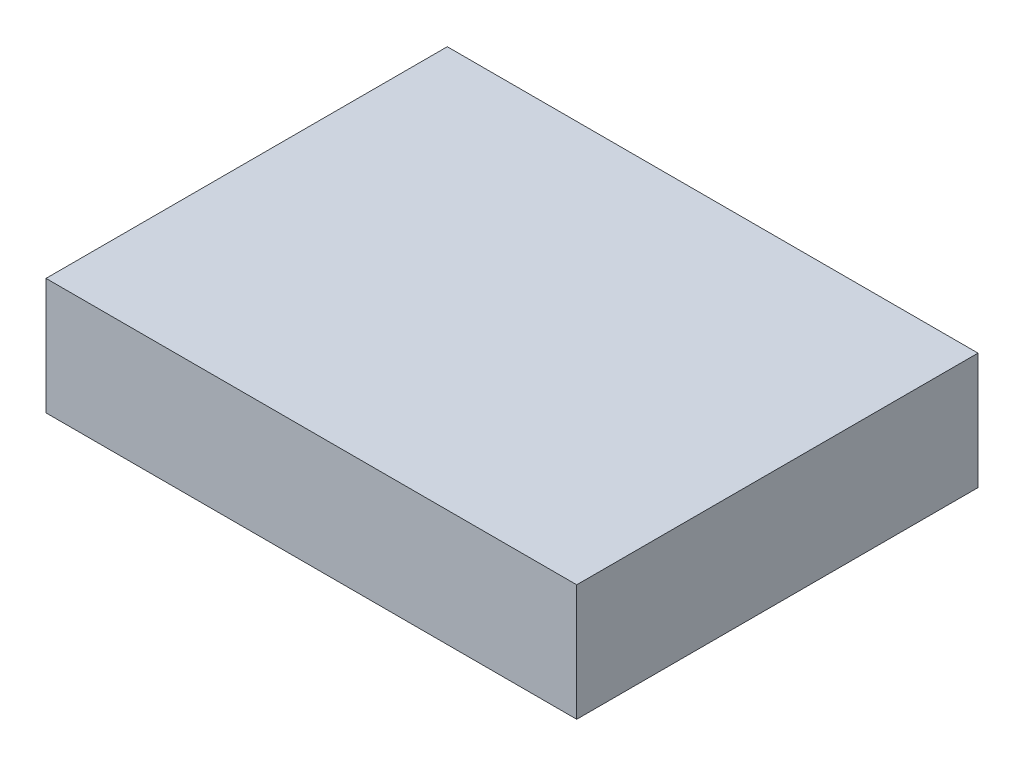
from build123d import *

# Parameters (mm, degrees)
SKETCH1_W           = 41
SKETCH1_H           = 31
BOSS_EXTRUDE1_DEPTH = 9


with BuildPart() as part:
    # Sketch1 → Boss-Extrude1 (new body)
    with BuildSketch(Plane(origin=(0, 0, 0), x_dir=(1, 0, 0), z_dir=(0, 1, 0))):
        with Locations((20.5, 15.5)):
            Rectangle(SKETCH1_W, SKETCH1_H)
    extrude(amount=BOSS_EXTRUDE1_DEPTH)


solid = part.part
